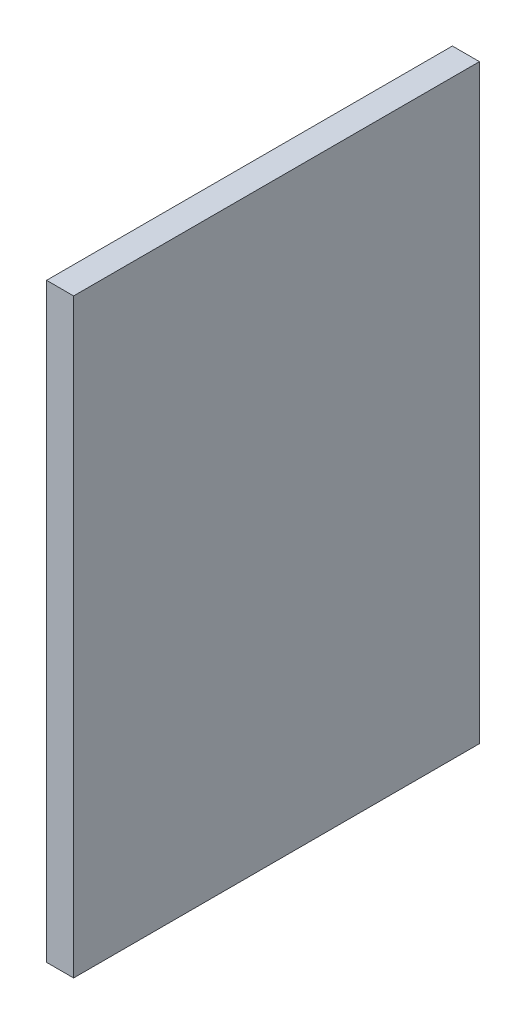
from build123d import *

# Parameters (mm, degrees)
SKETCH5_W           = 6.35
SKETCH5_H           = 138.638615584
BOSS_EXTRUDE1_DEPTH = 95.25


with BuildPart() as part:
    # Sketch5 → Boss-Extrude1 (new body)
    with BuildSketch(Plane.XY):
        with Locations((57.297607749, 241.830692208)):
            Rectangle(SKETCH5_W, SKETCH5_H)
    extrude(amount=BOSS_EXTRUDE1_DEPTH)


solid = part.part
